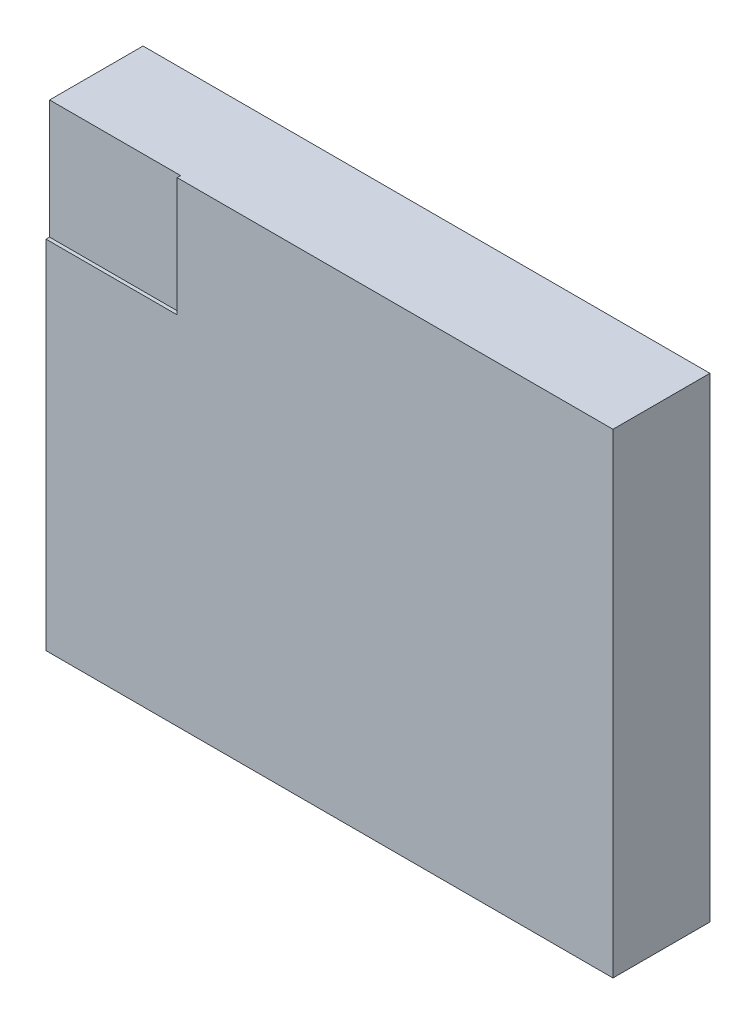
from build123d import *

# Parameters (mm, degrees)
BOSS_EXTRUDE1_START = 0.164
SKETCH1_W           = 1.608
SKETCH1_H           = 1.348
BOSS_EXTRUDE1_DEPTH = 0.275
SKETCH2_W           = 0.371806895
SKETCH2_H           = 0.337035884
CUT_EXTRUDE1_DEPTH  = 0.01
LPATTERN1_COUNT     = 2
LPATTERN1_PITCH     = 0.4
LPATTERN1_COL_COUNT = 2
LPATTERN1_COL_PITCH = 0.4


with BuildPart() as part:
    # Sketch1 → Boss-Extrude1 (new body)
    with BuildSketch(Plane.XY.offset(BOSS_EXTRUDE1_START)):
        Rectangle(SKETCH1_W, SKETCH1_H)
    extrude(amount=BOSS_EXTRUDE1_DEPTH)

    # Sketch2 → Cut-Extrude1 (cut)
    with BuildSketch(Plane.XY.offset(0.439)):
        with Locations((-0.618096553, 0.505482058)):
            Rectangle(SKETCH2_W, SKETCH2_H)
    extrude(amount=-CUT_EXTRUDE1_DEPTH, mode=Mode.SUBTRACT)

    # Sketch3 → Revolve5 (revolve)
    with BuildSketch(Plane(origin=(0, 0, 0), x_dir=(1, 0, 0), z_dir=(0, 1, 0))):
        with BuildLine():
            Line((-0.35, 0), (-0.35, -0.164))
            Line((-0.35, -0.164), (-0.259446149, -0.164))
            ThreePointArc((-0.259446149, -0.164), (-0.256330368, -0.055279598), (-0.35, 0))
        make_face()
    revolve5 = revolve(axis=Axis((-0.35, 0, 0), (0, 0, 1)))

    # LPattern1: Revolve5 ×2
    with Locations(*[(0, i * LPATTERN1_PITCH, 0) for i in range(1, LPATTERN1_COUNT)]):
        add(revolve5)

    # LPattern1 col: Revolve5 ×2
    with Locations(*[(0, -i * LPATTERN1_COL_PITCH, 0) for i in range(1, LPATTERN1_COL_COUNT)]):
        add(revolve5)

    # Sketch-Pattern1: Revolve5 at 2 more places
    with Locations((0.35, 0.2, 0), (0.35, -0.2, 0)):
        add(revolve5)

    # Mirror1: Revolve5 across plane
    add(revolve5.mirror(Plane(origin=(0, 0, 0), x_dir=(0, 0, 1), z_dir=(1, 0, 0))))

    # Mirror1 copy 1 sketch → Mirror1 copy 1 (revolve)
    with BuildSketch(Plane(origin=(0, 0.4, 0), x_dir=(-1, 0, 0), z_dir=(0, 1, 0))):
        with BuildLine():
            Line((-0.35, 0), (-0.35, 0.164))
            Line((-0.35, 0.164), (-0.259446149, 0.164))
            ThreePointArc((-0.259446149, 0.164), (-0.256330368, 0.055279598), (-0.35, 0))
        make_face()
    revolve(axis=Axis((0.35, 0.4, 0), (0, 0, -1)))

    # Mirror1 copy 2 sketch → Mirror1 copy 2 (revolve)
    with BuildSketch(Plane(origin=(0, -0.4, 0), x_dir=(-1, 0, 0), z_dir=(0, 1, 0))):
        with BuildLine():
            Line((-0.35, 0), (-0.35, 0.164))
            Line((-0.35, 0.164), (-0.259446149, 0.164))
            ThreePointArc((-0.259446149, 0.164), (-0.256330368, 0.055279598), (-0.35, 0))
        make_face()
    revolve(axis=Axis((0.35, -0.4, 0), (0, 0, -1)))


solid = part.part
